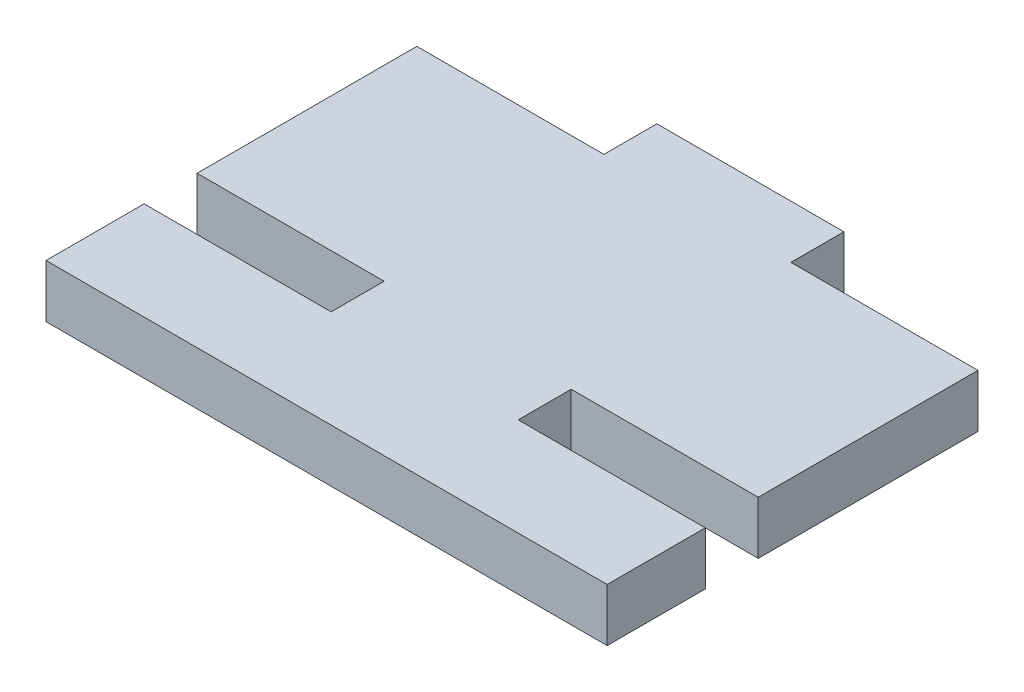
from build123d import *

# Parameters (mm, degrees)
BOSS_EXTRUDE1_DEPTH = 2.7


with BuildPart() as part:
    # Sketch1 → Boss-Extrude1 (new body)
    with BuildSketch(Plane(origin=(0, 0, 0), x_dir=(1, 0, 0), z_dir=(0, 1, 0))):
        Polygon((-14.3, -6.95), (-4.766666667, -6.95), (-4.766666667, -4.25), (-14.3, -4.25), (-14.3, 6.95), (-4.766666667, 6.95), (-4.766666667, 9.65), (4.766666667, 9.65), (4.766666667, 6.95), (14.3, 6.95), (14.3, -4.25), (4.766666667, -4.25), (4.766666667, -6.95), (14.3, -6.95), (14.3, -11.95), (-14.3, -11.95), align=None)
    extrude(amount=BOSS_EXTRUDE1_DEPTH)


solid = part.part
